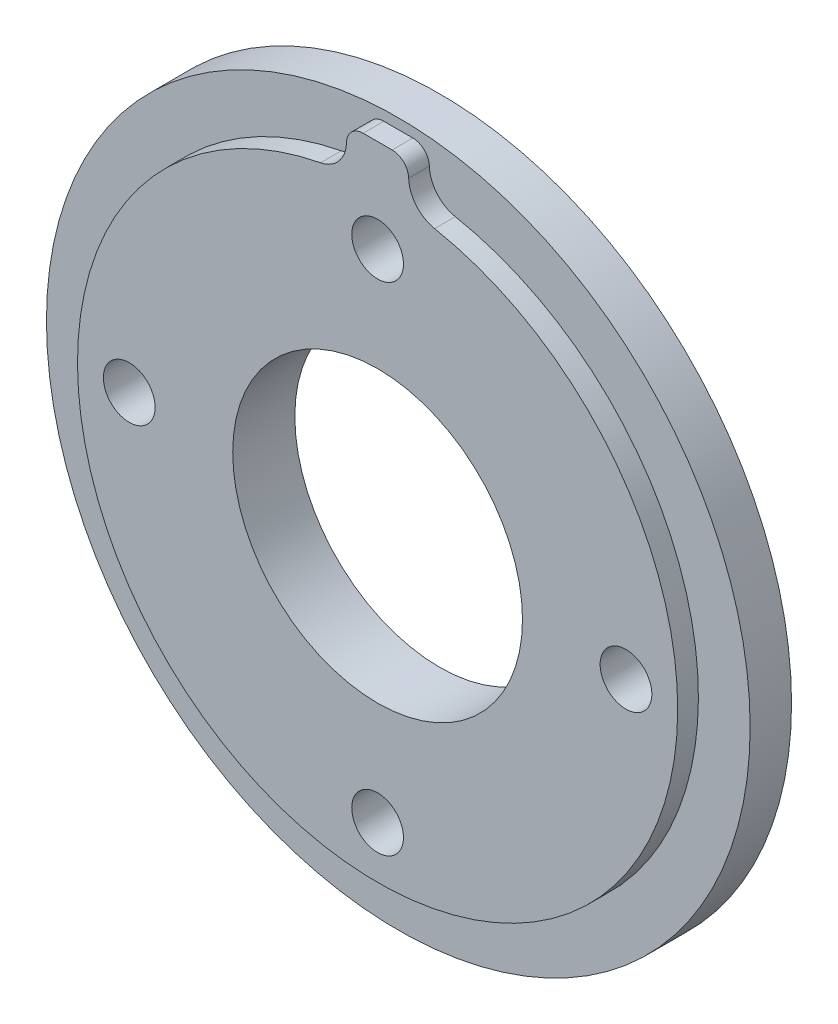
from build123d import *

# Parameters (mm, degrees)
SKETCH_1_R          = 17
EXTRUDE_1_DEPTH     = 2
EXTRUDE_2_DEPTH     = 1
FILLET_1_R          = 1.55
FILLET_2_R          = 0.8
SKETCH_3_R          = 7
CUT_EXTRUDE_1_DEPTH = 4
SKETCH_4_R          = 1.25
CUT_EXTRUDE_2_DEPTH = 4.0000001


with BuildPart() as part:
    # ｽｹｯﾁ1 → ﾎﾞｽ - 押し出し1 (new body)
    with BuildSketch(Plane.XY):
        Circle(SKETCH_1_R)
    extrude(amount=EXTRUDE_1_DEPTH)

    # ｽｹｯﾁ2 → ﾎﾞｽ - 押し出し2 (add)
    with BuildSketch(Plane.XY.offset(2)):
        with BuildLine():
            Line((-1.5, 14.422205102), (-1.5, 12.5))
            Line((-1.5, 12.5), (1.5, 12.5))
            Line((1.5, 12.5), (1.5, 14.422205102))
            ThreePointArc((1.5, 14.422205102), (0, 14.5), (-1.5, 14.422205102))
        make_face()
        with BuildLine():
            Line((1.5, 12.5), (-1.5, 12.5))
            Line((-1.5, 12.5), (-1.5, 14.422205102))
            ThreePointArc((-1.5, 14.422205102), (-9.708243919, -10.770329614), (14.5, 0))
            ThreePointArc((14.5, 0), (10.770329614, 9.708243919), (1.5, 14.422205102))
            Line((1.5, 14.422205102), (1.5, 12.5))
        make_face()
        with BuildLine():
            Line((-1.5, 16.5), (-1.5, 14.422205102))
            ThreePointArc((-1.5, 14.422205102), (0, 14.5), (1.5, 14.422205102))
            Line((1.5, 14.422205102), (1.5, 16.5))
            Line((1.5, 16.5), (-1.5, 16.5))
        make_face()
    extrude(amount=EXTRUDE_2_DEPTH)

    # ﾌｨﾚｯﾄ1
    fillet_1_edges = [part.edges().sort_by_distance(p)[0] for p in [
        (-1.5, 14.422205102, 2.5),
        (1.5, 14.422205102, 2.5),
    ]]
    fillet(fillet_1_edges, radius=FILLET_1_R)

    # ﾌｨﾚｯﾄ2
    fillet_2_edges = [part.edges().sort_by_distance(p)[0] for p in [
        (1.5, 16.5, 2.5),
        (-1.5, 16.5, 2.5),
    ]]
    fillet(fillet_2_edges, radius=FILLET_2_R)

    # ｽｹｯﾁ3 → ｶｯﾄ - 押し出し1 (cut, through all)
    with BuildSketch(Plane.XY.offset(3)):
        Circle(SKETCH_3_R)
    extrude(amount=-CUT_EXTRUDE_1_DEPTH, mode=Mode.SUBTRACT)

    # ｽｹｯﾁ4 → ｶｯﾄ - 押し出し2 (cut, through all)
    with BuildSketch(Plane(origin=(0, 0, 0), x_dir=(-1, 0, 0), z_dir=(0, 0, -1))):
        with Locations((0, 12)):
            Circle(SKETCH_4_R)
        with Locations((12, 0)):
            Circle(SKETCH_4_R)
        with Locations((0, -12)):
            Circle(SKETCH_4_R)
        with Locations((-12, 0)):
            Circle(SKETCH_4_R)
    extrude(amount=-CUT_EXTRUDE_2_DEPTH, mode=Mode.SUBTRACT)


solid = part.part
